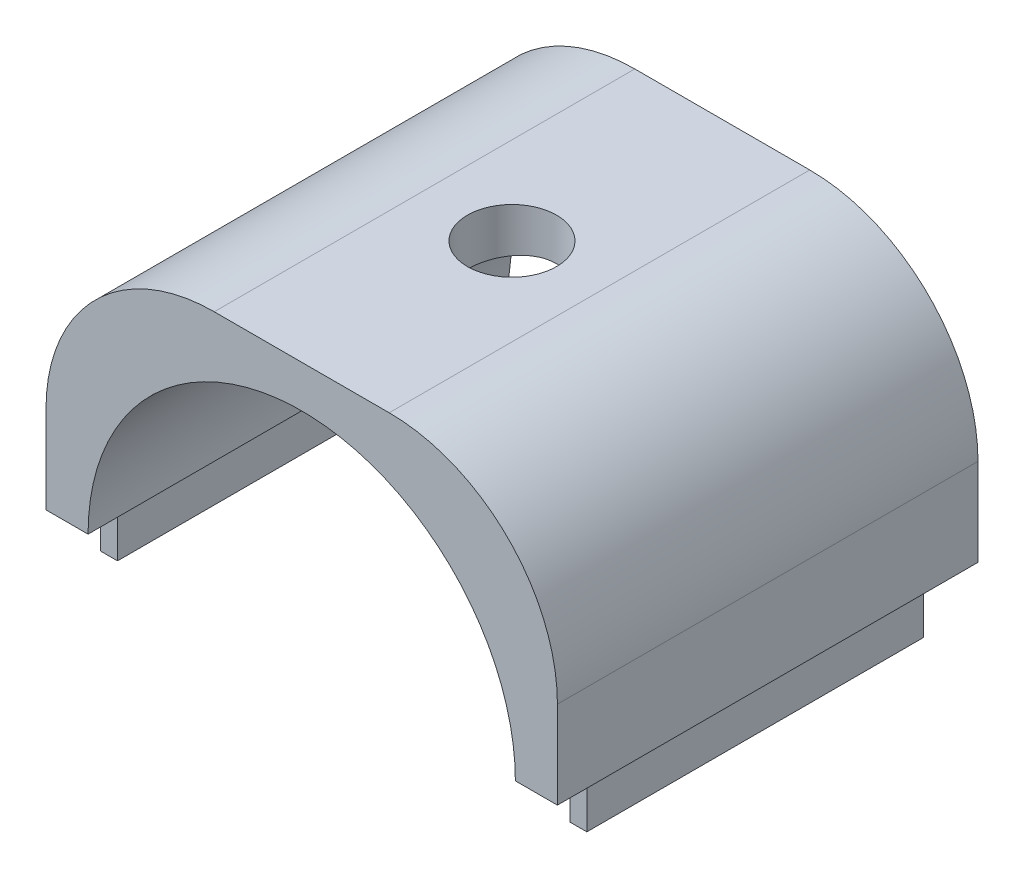
from build123d import *

# Parameters (mm, degrees)
BOSS_EXTRUDE1_DEPTH  = 12.5
M5_CLEARANCE_HOLE1_D = 5.3
SKETCH4_W            = 1
SKETCH4_H            = 20
BOSS_EXTRUDE2_DEPTH  = 3


with BuildPart() as part:
    # Sketch1 → Boss-Extrude1 (new body, symmetric)
    with BuildSketch(Plane.XY):
        with BuildLine():
            Line((-15.2, 0), (-12.7, 0))
            ThreePointArc((-12.7, 0), (0, 12.7), (12.7, 0))
            Line((12.7, 0), (15.2, 0))
            Line((15.2, 0), (15.2, 5.2))
            ThreePointArc((15.2, 5.2), (12.271067812, 12.271067812), (5.2, 15.2))
            Line((5.2, 15.2), (-5.2, 15.2))
            ThreePointArc((-5.2, 15.2), (-12.271067812, 12.271067812), (-15.2, 5.2))
            Line((-15.2, 5.2), (-15.2, 0))
        make_face()
    extrude(amount=BOSS_EXTRUDE1_DEPTH, both=True)

    # M5 Clearance Hole1 (through all)
    with Locations(Plane(origin=(0, 15.2, 0), x_dir=(1, 0, 0), z_dir=(0, 1, 0))):
        with Locations((0, 0)):
            Hole(M5_CLEARANCE_HOLE1_D / 2)

    # Sketch4 → Boss-Extrude2 (add)
    with BuildSketch(Plane.XZ):
        with Locations((-13.95, 0)):
            Rectangle(SKETCH4_W, SKETCH4_H)
        with Locations((13.95, 0)):
            Rectangle(SKETCH4_W, SKETCH4_H)
    extrude(amount=BOSS_EXTRUDE2_DEPTH)


solid = part.part
